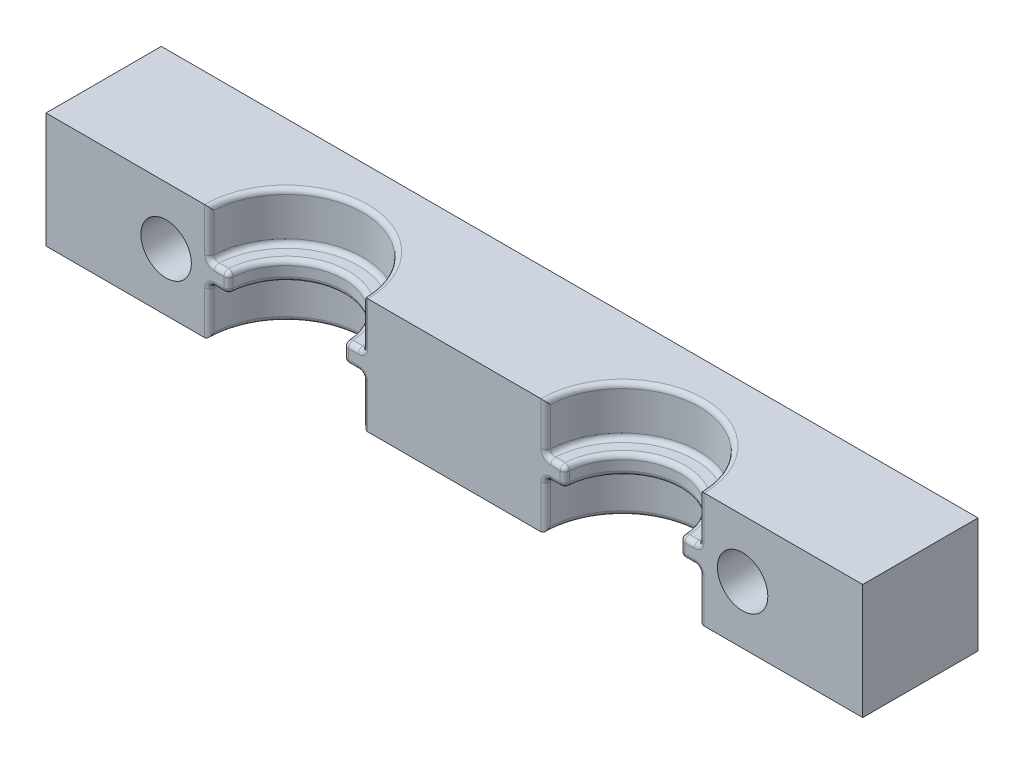
from build123d import *

# Parameters (mm, degrees)
SKETCH1_W               = 85
SKETCH1_H               = 12
BOSS_EXTRUDE1_DEPTH     = 12
SKETCH2_R               = 8
CUT_EXTRUDE2_DEPTH      = 5
SKETCH3_R               = 8
CUT_EXTRUDE3_DEPTH      = 5
SKETCH4_R               = 6
CUT_EXTRUDE4_DEPTH      = 7
CUT_EXTRUDE4_DEPTH_BACK = 7
SKETCH5_R               = 2.625
CUT_EXTRUDE6_DEPTH      = 13
FILLET1_R               = 0.5


with BuildPart() as part:
    # Sketch1 → Boss-Extrude1 (new body)
    with BuildSketch(Plane.XY):
        Rectangle(SKETCH1_W, SKETCH1_H)
    extrude(amount=BOSS_EXTRUDE1_DEPTH)

    # Sketch2 → Cut-Extrude2 (cut)
    with BuildSketch(Plane(origin=(0, 6, 0), x_dir=(1, 0, 0), z_dir=(0, 1, 0))):
        with Locations((-17.5, -12)):
            Circle(SKETCH2_R)
        with Locations((17.5, -12)):
            Circle(SKETCH2_R)
    extrude(amount=-CUT_EXTRUDE2_DEPTH, mode=Mode.SUBTRACT)

    # Sketch3 → Cut-Extrude3 (cut)
    with BuildSketch(Plane.XZ.offset(6)):
        with Locations((-17.5, 12)):
            Circle(SKETCH3_R)
        with Locations((17.5, 12)):
            Circle(SKETCH3_R)
    extrude(amount=-CUT_EXTRUDE3_DEPTH, mode=Mode.SUBTRACT)

    # Sketch4 → Cut-Extrude4 (cut, two sides)
    with BuildSketch(Plane(origin=(0, 0, 0), x_dir=(1, 0, 0), z_dir=(0, 1, 0))) as cut_extrude4_sk:
        with Locations((-17.5, -12)):
            Circle(SKETCH4_R)
        with Locations((17.5, -12)):
            Circle(SKETCH4_R)
    extrude(amount=CUT_EXTRUDE4_DEPTH, mode=Mode.SUBTRACT)
    extrude(cut_extrude4_sk.sketch, amount=-CUT_EXTRUDE4_DEPTH_BACK, mode=Mode.SUBTRACT)

    # Sketch5 → Cut-Extrude6 (cut, through all)
    with BuildSketch(Plane.XY.offset(12)):
        with Locations((-30, 0)):
            Circle(SKETCH5_R)
        with Locations((30, 0)):
            Circle(SKETCH5_R)
    extrude(amount=-CUT_EXTRUDE6_DEPTH, mode=Mode.SUBTRACT)

    # Fillet1
    fillet1_edges = [part.edges().sort_by_distance(p)[0] for p in [
        (-24.5, 1, 12),
        (-9.5, 3.5, 12),
        (-25.5, 3.5, 12),
        (-17.5, 1, 4),
        (-17.5, 6, 4),
        (10.5, 1, 12),
        (25.5, 3.5, 12),
        (9.5, 3.5, 12),
        (17.5, 1, 4),
        (17.5, 6, 4),
        (-10.5, -1, 12),
        (-25.5, -3.5, 12),
        (-9.5, -3.5, 12),
        (-17.5, -1, 4),
        (-17.5, -6, 4),
        (24.5, -1, 12),
        (9.5, -3.5, 12),
        (25.5, -3.5, 12),
        (17.5, -1, 4),
        (17.5, -6, 4),
        (-24.5, -1, 12),
        (-17.5, -1, 6),
        (-10.5, 1, 12),
        (-17.5, 1, 6),
        (-11.5, 0, 12),
        (-23.5, 0, 12),
        (10.5, -1, 12),
        (17.5, -1, 6),
        (24.5, 1, 12),
        (17.5, 1, 6),
        (23.5, 0, 12),
        (11.5, 0, 12),
    ]]
    fillet(fillet1_edges, radius=FILLET1_R)


solid = part.part
